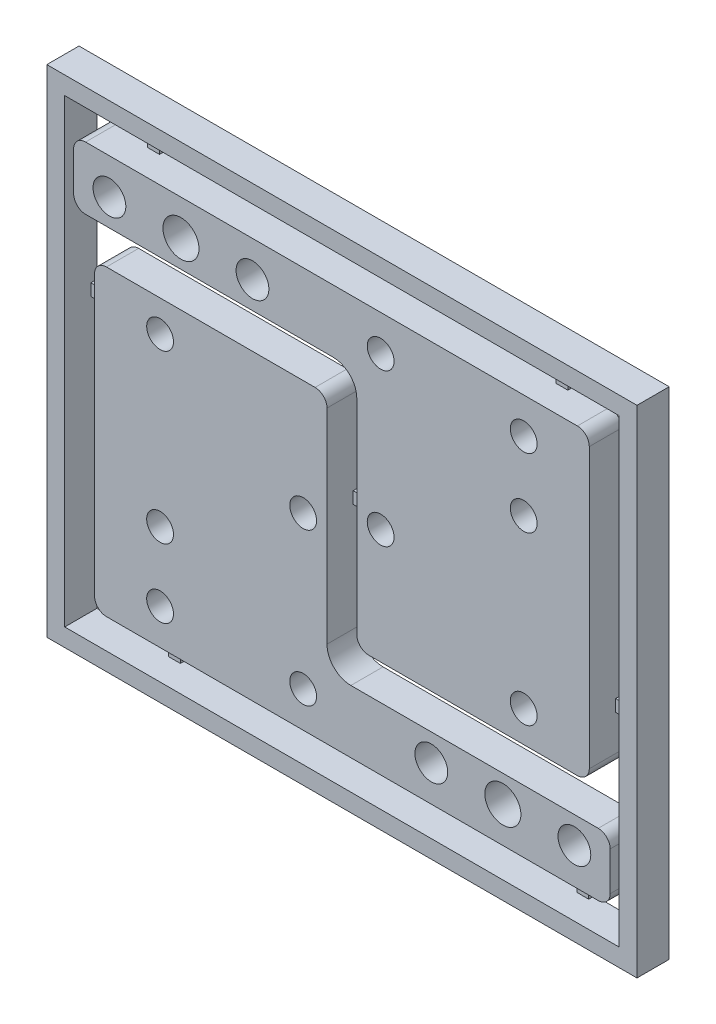
from build123d import *

# Parameters (mm, degrees)
SKETCH1_R           = 2.75
SKETCH1_R_2         = 2.25
BOSS_EXTRUDE1_DEPTH = 5.4
FILLET1_R           = 4
SKETCH2_R           = 3.025
CUT_EXTRUDE1_DEPTH  = 6.4
SKETCH3_R           = 2.25
CUT_EXTRUDE2_DEPTH  = 5
CIRPATTERN1_COUNT   = 2
FILLET2_R           = 2
FILLET3_R           = 2
SKETCH5_W           = 99
SKETCH5_H           = 83.2
SKETCH5_W_2         = 93
SKETCH5_H_2         = 77.2
BOSS_EXTRUDE3_DEPTH = 5.4
SKETCH6_W           = 5
SKETCH6_H           = 2
SKETCH6_W_2         = 2
SKETCH6_H_2         = 5
BOSS_EXTRUDE4_DEPTH = 1


with BuildPart() as part:
    # Sketch1 → Boss-Extrude1 (new body)
    with BuildSketch(Plane.XY):
        Polygon((0, 0), (86.5, 0), (86.5, 10.5), (39, 10.5), (39, 50.8), (0, 50.8), align=None)
        with Locations((56.5, 6)):
            Circle(SKETCH1_R, mode=Mode.SUBTRACT)
        with Locations((11, 17.55)):
            Circle(SKETCH1_R_2, mode=Mode.SUBTRACT)
        with Locations((80.5, 6)):
            Circle(SKETCH1_R, mode=Mode.SUBTRACT)
        with Locations((11, 45.55)):
            Circle(SKETCH1_R_2, mode=Mode.SUBTRACT)
        with Locations((35, 31.55)):
            Circle(SKETCH1_R_2, mode=Mode.SUBTRACT)
    extrude(amount=BOSS_EXTRUDE1_DEPTH)

    # Fillet1
    fillet1_edges = [part.edges().sort_by_distance(p)[0] for p in [
        (39, 10.5, 2.7),
    ]]
    fillet(fillet1_edges, radius=FILLET1_R)

    # Sketch2 → Cut-Extrude1 (cut, through all)
    with BuildSketch(Plane.XY.offset(5.4)):
        with Locations((68.5, 6)):
            Circle(SKETCH2_R)
    extrude(amount=-CUT_EXTRUDE1_DEPTH, mode=Mode.SUBTRACT)

    # Sketch3 → Cut-Extrude2 (cut)
    with BuildSketch(Plane.XY.offset(5.4)):
        with Locations((11, 6)):
            Circle(SKETCH3_R)
        with Locations((35, 6)):
            Circle(SKETCH3_R)
    extrude(amount=-CUT_EXTRUDE2_DEPTH, mode=Mode.SUBTRACT)


with BuildPart() as cirpattern1_1:
    # CirPattern1: pattern copy
    add(part.part.rotate(Axis((41.5, 33.6, 0), (0, 0, 1)), 1 * 360 / CIRPATTERN1_COUNT))

    # Fillet2
    fillet2_edges = [cirpattern1_1.edges().sort_by_distance(p)[0] for p in [
        (83, 16.4, 2.7),
        (44, 16.4, 2.7),
        (-3.5, 56.7, 2.7),
        (-3.5, 67.2, 2.7),
        (83, 67.2, 2.7),
    ]]
    fillet(fillet2_edges, radius=FILLET2_R)


with BuildPart() as part_1:
    add(part.part)

    # Fillet3
    fillet3_edges = [part_1.edges().sort_by_distance(p)[0] for p in [
        (0, 50.8, 2.7),
        (39, 50.8, 2.7),
        (86.5, 10.5, 2.7),
        (86.5, 0, 2.7),
        (0, 0, 2.7),
    ]]
    fillet(fillet3_edges, radius=FILLET3_R)

    add(cirpattern1_1.part)  # Boss-Extrude4 merges CirPattern1_1


with BuildPart() as body_3:
    # Sketch5 → Boss-Extrude3 (new body)
    with BuildSketch(Plane(origin=(0, 0, 0), x_dir=(-1, 0, 0), z_dir=(0, 0, -1))):
        with Locations((-41.5, 33.6)):
            Rectangle(SKETCH5_W, SKETCH5_H)
        with Locations((-41.5, 33.6)):
            Rectangle(SKETCH5_W_2, SKETCH5_H_2, mode=Mode.SUBTRACT)
    extrude(amount=-BOSS_EXTRUDE3_DEPTH)


with BuildPart() as part_2:
    add(part_1.part)

    add(body_3.part)  # Boss-Extrude4 merges body 3
    # Sketch6 → Boss-Extrude4 (add)
    with BuildSketch(Plane(origin=(0, 0, 0), x_dir=(-1, 0, 0), z_dir=(0, 0, -1))):
        with Locations((-41.5, 33.6)):
            Rectangle(SKETCH6_W, SKETCH6_H)
        with Locations((2.5, 41.8)):
            Rectangle(SKETCH6_W, SKETCH6_H)
        with Locations((-9, -2.5)):
            Rectangle(SKETCH6_W_2, SKETCH6_H_2)
        with Locations((-77.5, -2.5)):
            Rectangle(SKETCH6_W_2, SKETCH6_H_2)
        with Locations((-85.5, 25.4)):
            Rectangle(SKETCH6_W, SKETCH6_H)
        with Locations((-74, 69.7)):
            Rectangle(SKETCH6_W_2, SKETCH6_H_2)
        with Locations((-5.5, 69.7)):
            Rectangle(SKETCH6_W_2, SKETCH6_H_2)
    extrude(amount=-BOSS_EXTRUDE4_DEPTH)


solid = part_2.part
